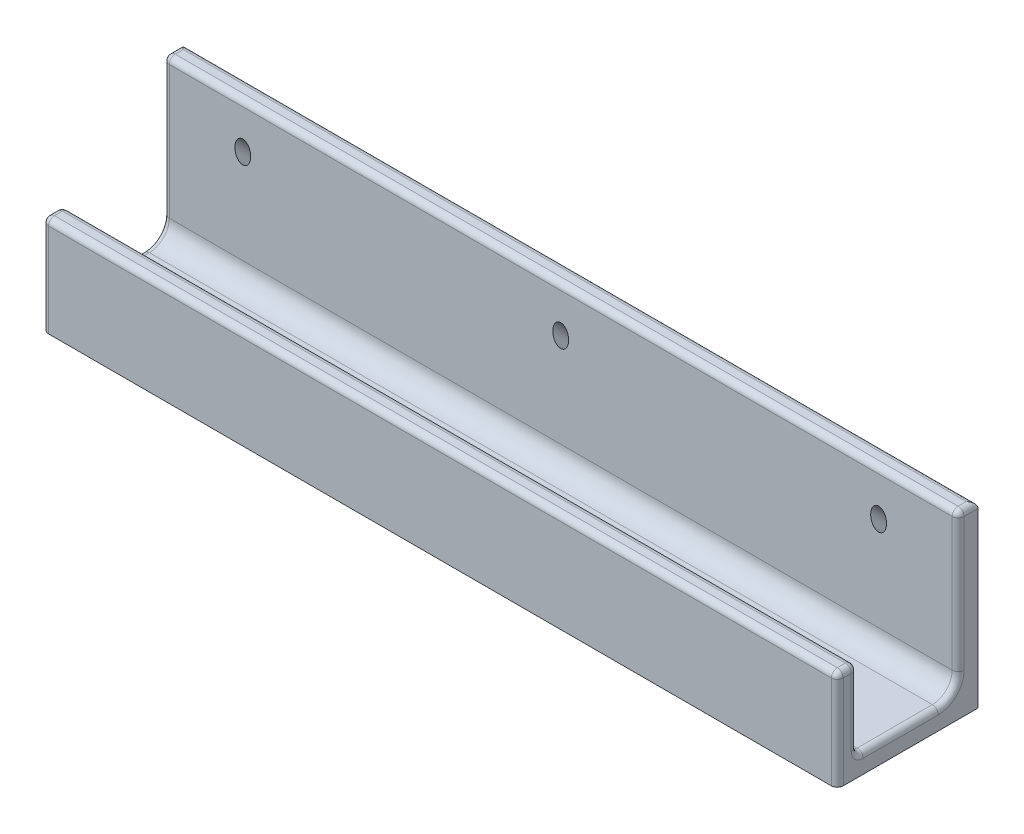
from build123d import *

# Parameters (mm, degrees)
EXTRUDE_THIN1_DEPTH      = 100
F_4_0_4_DIAMETER_HOLE1_D = 4
FILLET3_R                = 5
FILLET2_R                = 1.5


with BuildPart() as part:
    # Sketch1 → Extrude-Thin1 (new body, symmetric)
    with BuildSketch(Plane(origin=(0, 0, 0), x_dir=(0, 0, -1), z_dir=(1, 0, 0))):
        Polygon((12.7, 40), (12.7, 0), (0, 0), (-12.7, 0), (-12.7, 20), (-17.7, 20), (-17.7, -5), (0, -5), (17.7, -5), (17.7, 40), align=None)
    extrude(amount=EXTRUDE_THIN1_DEPTH, both=True)

    # Ø4.0 (4) Diameter Hole1 (through all)
    with Locations(Plane(origin=(0, 13.65, 13.65), x_dir=(-1, 0, 0), z_dir=(0, 0.707106781, 0.707106781))):
        with Locations((80, -29.264527369), (-80, -29.264527369), (0, -29.264527369)):
            Hole(F_4_0_4_DIAMETER_HOLE1_D / 2)

    # Fillet3
    fillet3_edges = [part.edges().sort_by_distance(p)[0] for p in [
        (0, 0, -12.7),
    ]]
    fillet(fillet3_edges, radius=FILLET3_R)

    # Fillet2
    fillet2_edges = [part.edges().sort_by_distance(p)[0] for p in [
        (-100, 10, 12.7),
        (-100, 0, 2.5),
        (-100, 40, -15.2),
        (0, 20, 17.7),
        (0, 20, 12.7),
        (0, 0, 12.7),
        (0, 40, -12.7),
        (0, 40, -17.7),
        (100, 0, 2.5),
        (100, 10, 12.7),
        (100, 20, 15.2),
        (100, 7.5, 17.7),
        (-100, 22.5, -12.7),
        (100, 22.5, -12.7),
        (-100, 1.464466094, -11.235533906),
        (100, 1.464466094, -11.235533906),
        (100, 40, -15.2),
        (-100, 7.5, 17.7),
        (-100, 20, 15.2),
    ]]
    fillet(fillet2_edges, radius=FILLET2_R)


solid = part.part
